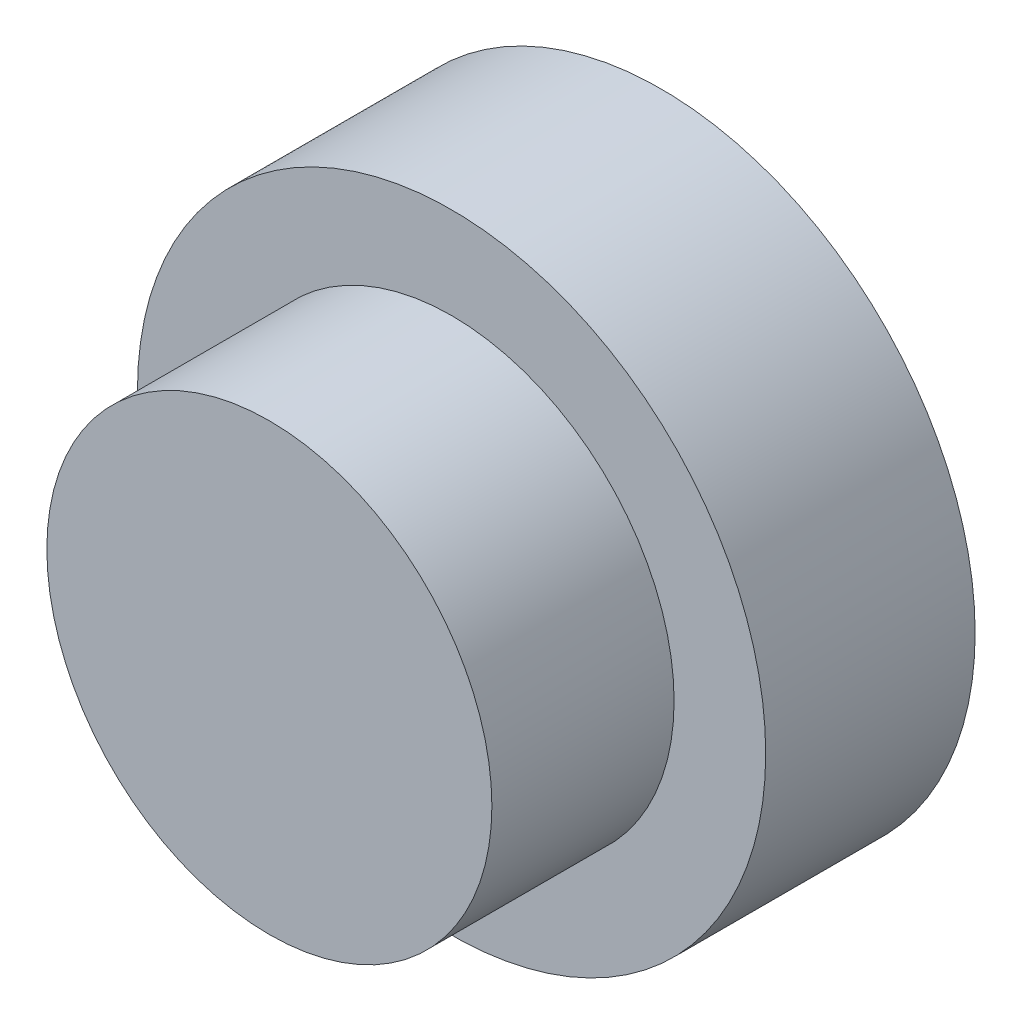
from build123d import *

# Parameters (mm, degrees)
SKETCH1_R           = 38.1
SKETCH1_R_2         = 9.525
BOSS_EXTRUDE1_DEPTH = 25.4
SKETCH2_R           = 26.9875
BOSS_EXTRUDE3_DEPTH = 47.498


with BuildPart() as part:
    # Sketch1 → Boss-Extrude1 (new body)
    with BuildSketch(Plane.XY):
        Circle(SKETCH1_R)
        Circle(SKETCH1_R_2, mode=Mode.SUBTRACT)
    extrude(amount=BOSS_EXTRUDE1_DEPTH)

    # Sketch2 → Boss-Extrude3 (add)
    with BuildSketch(Plane(origin=(0, 0, 0), x_dir=(-1, 0, 0), z_dir=(0, 0, -1))):
        Circle(SKETCH2_R)
    extrude(amount=-BOSS_EXTRUDE3_DEPTH)


solid = part.part
